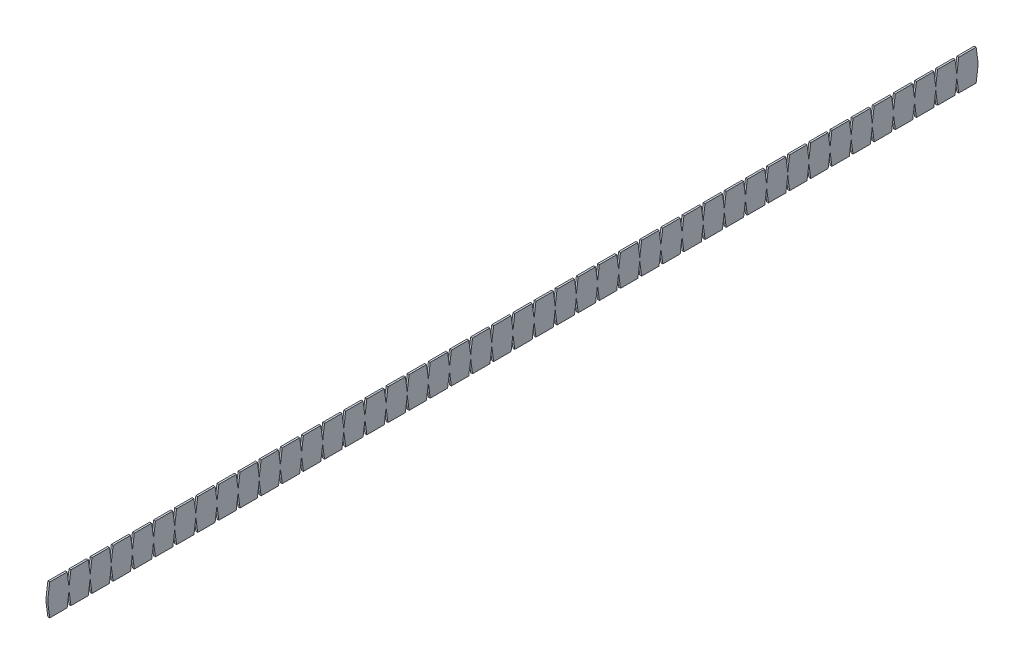
from build123d import *

# Parameters (mm, degrees)
BOSS_EXTRUDE1_DEPTH = 3.048
LPATTERN1_COUNT     = 44
LPATTERN1_PITCH     = 34.544


with BuildPart() as part:
    # Sketch2 → Boss-Extrude1 (new body)
    with BuildSketch(Plane(origin=(0, 0, 0), x_dir=(0, 0, -1), z_dir=(1, 0, 0))):
        Polygon((-34.544, 0), (-31.496, 22.86), (-3.048, 22.86), (0, 0), (0, -5.08), (-3.048, -27.94), (-31.496, -27.94), (-34.544, -5.08), align=None)
    boss_extrude1 = extrude(amount=BOSS_EXTRUDE1_DEPTH)

    # LPattern1: Boss-Extrude1 ×44
    with Locations(*[(0, 0, -i * LPATTERN1_PITCH) for i in range(1, LPATTERN1_COUNT)]):
        add(boss_extrude1)


solid = part.part
